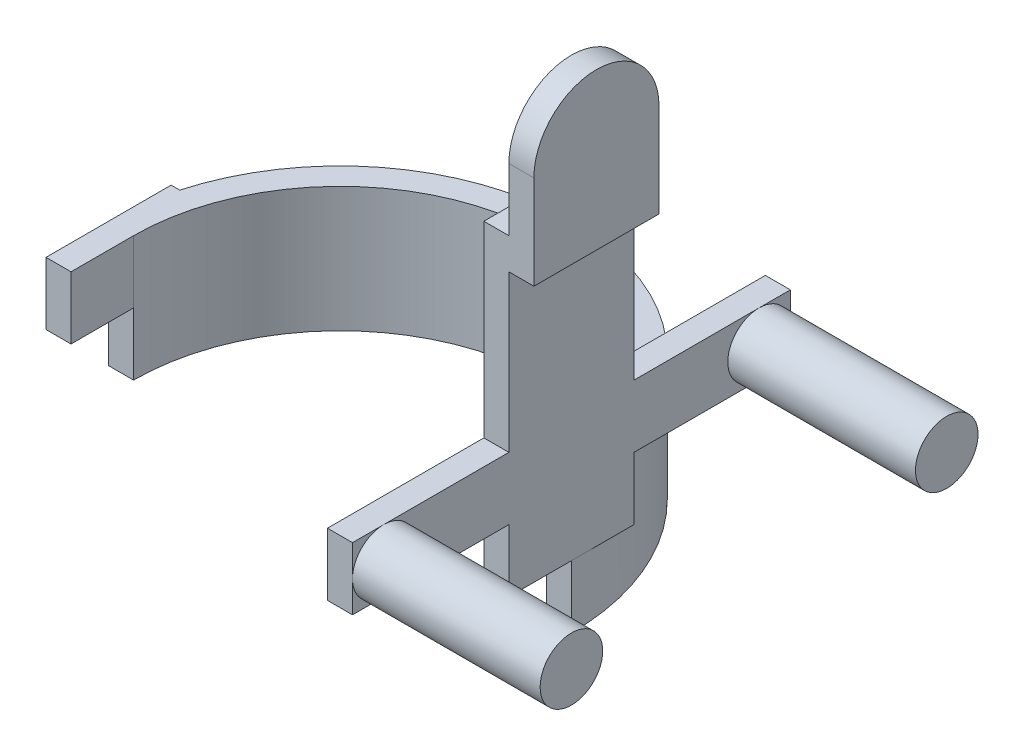
from build123d import *

# Parameters (mm, degrees)
EXTRUDE_1_DEPTH     = 40
SKETCH_2_W          = 8
SKETCH_2_H          = 40
EXTRUDE_2_DEPTH     = 80
SKETCH_4_W          = 49.783903804
SKETCH_4_H          = 113.982309312
CUT_EXTRUDE_3_DEPTH = 10
SKETCH_5_R          = 84.762192866
CUT_EXTRUDE_4_DEPTH = 20
SKETCH_6_W          = 140
SKETCH_6_H          = 20
EXTRUDE_3_DEPTH     = 8
SKETCH_7_R          = 10
EXTRUDE_4_DEPTH     = 60
SKETCH_9_W          = 8
SKETCH_9_H          = 50
EXTRUDE_5_DEPTH     = 40
CUT_EXTRUDE_5_DEPTH = 40


with BuildPart() as part:
    # 草图1 → 凸台-拉伸1 (new body)
    with BuildSketch(Plane(origin=(0, 0, 0), x_dir=(1, 0, 0), z_dir=(0, 1, 0))):
        with BuildLine():
            Line((-74, 20), (-71.246052522, 20))
            ThreePointArc((-71.246052522, 20), (0, 74), (71.246052522, 20))
            Line((71.246052522, 20), (74, 20))
            Line((74, 20), (74, -20))
            Line((74, -20), (66, -20))
            Line((66, -20), (66, 0))
            ThreePointArc((66, 0), (0, 66), (-66, 0))
            Line((-66, 0), (-66, -20))
            Line((-66, -20), (-74, -20))
            Line((-74, -20), (-74, 20))
        make_face()
    extrude(amount=EXTRUDE_1_DEPTH)

    # 草图2 → 凸台-拉伸2 (add)
    with BuildSketch(Plane(origin=(0, 40, 0), x_dir=(1, 0, 0), z_dir=(0, 1, 0))):
        with Locations((-70, 0)):
            Rectangle(SKETCH_2_W, SKETCH_2_H)
        with Locations((70, 0)):
            Rectangle(SKETCH_2_W, SKETCH_2_H)
    extrude(amount=EXTRUDE_2_DEPTH)

    # 草图4 → 切除-拉伸3 (cut)
    with BuildSketch(Plane.ZY.offset(74)):
        with Locations((4.891951902, 96.991154656)):
            Rectangle(SKETCH_4_W, SKETCH_4_H)
    extrude(amount=-CUT_EXTRUDE_3_DEPTH, mode=Mode.SUBTRACT)

    # 草图5 → 切除-拉伸4 (cut)
    with BuildSketch(Plane.XZ):
        Circle(SKETCH_5_R)
        with BuildLine():
            Line((-71.246052522, 20), (-66, 20))
            Line((-66, 20), (-66, 0))
            Line((-66, 0), (-74, 0))
            ThreePointArc((-74, 0), (0, -74), (74, 0))
            Line((74, 0), (66, 0))
            Line((66, 0), (66, 20))
            Line((66, 20), (71.246052522, 20))
            ThreePointArc((71.246052522, 20), (0, 74), (-71.246052522, 20))
        make_face(mode=Mode.SUBTRACT)
    extrude(amount=-CUT_EXTRUDE_4_DEPTH, mode=Mode.SUBTRACT)

    # 草图6 → 凸台-拉伸3 (add)
    with BuildSketch(Plane(origin=(74, 0, 0), x_dir=(0, 0, -1), z_dir=(1, 0, 0))):
        with Locations((0, 50)):
            Rectangle(SKETCH_6_W, SKETCH_6_H)
    extrude(amount=-EXTRUDE_3_DEPTH)

    # 草图7 → 凸台-拉伸4 (add)
    with BuildSketch(Plane(origin=(74, 0, 0), x_dir=(0, 0, -1), z_dir=(1, 0, 0))):
        with Locations((-60, 50)):
            Circle(SKETCH_7_R)
        with Locations((60, 50)):
            Circle(SKETCH_7_R)
    extrude(amount=EXTRUDE_4_DEPTH)

    # 草图9 → 凸台-拉伸5 (add)
    with BuildSketch(Plane(origin=(0, 0, -20), x_dir=(-1, 0, 0), z_dir=(0, 0, -1))):
        with Locations((-78, 135)):
            Rectangle(SKETCH_9_W, SKETCH_9_H)
    extrude(amount=-EXTRUDE_5_DEPTH)

    # 草图10 → 切除-拉伸5 (cut)
    with BuildSketch(Plane(origin=(82, 0, 0), x_dir=(0, 0, -1), z_dir=(1, 0, 0))):
        with BuildLine():
            Line((-20, 140), (-20, 173.0765562))
            Line((-20, 173.0765562), (20, 173.0765562))
            Line((20, 173.0765562), (20, 140))
            ThreePointArc((20, 140), (0, 160), (-20, 140))
        make_face()
    extrude(amount=-CUT_EXTRUDE_5_DEPTH, mode=Mode.SUBTRACT)


solid = part.part
